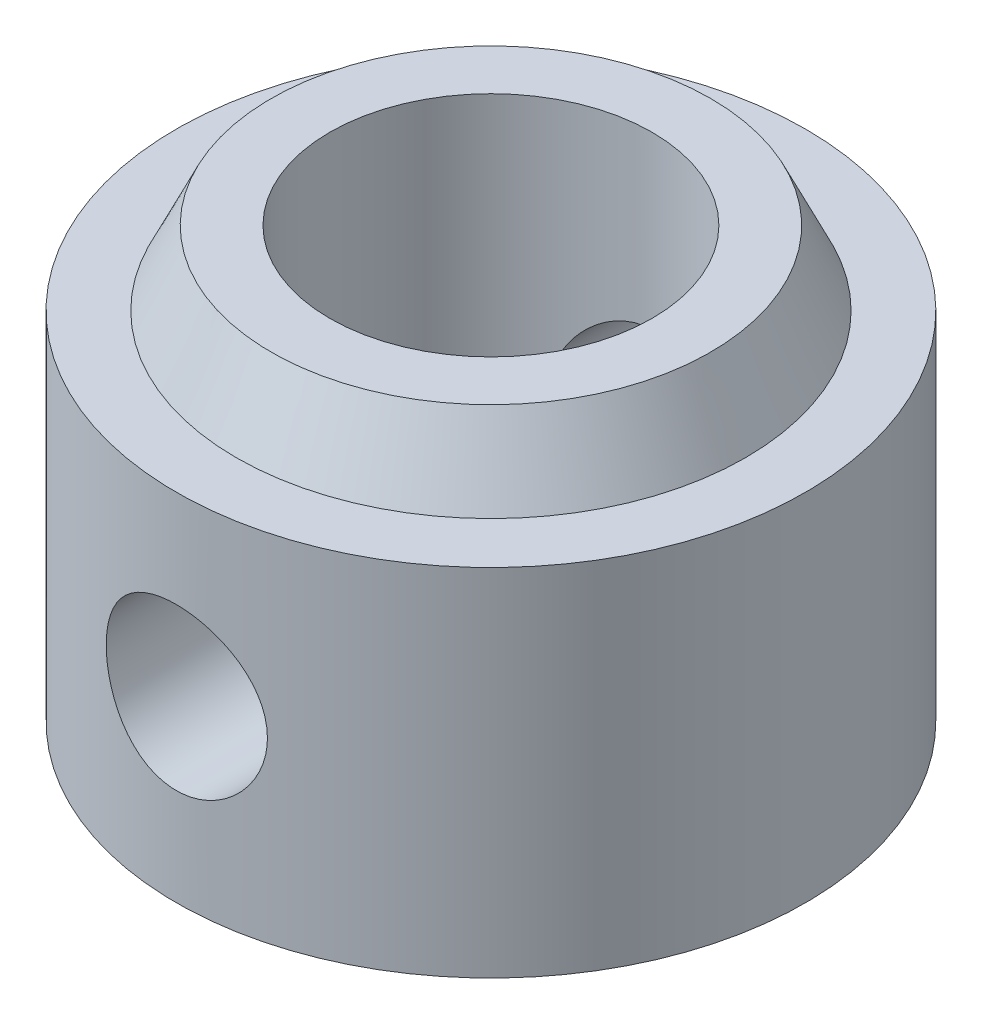
from build123d import *

# Parameters (mm, degrees)
M2_5X0_45_TAPPED_HOLE1_D = 2.05


with BuildPart() as part:
    # Sketch2 → Revolve1 (revolve)
    with BuildSketch(Plane.XY):
        Polygon((2.05, 5.461), (2.05, 0), (4.0005, 0), (4.0005, 4.5212), (3.2385, 4.5212), (2.794, 5.461), align=None)
    revolve(axis=Axis((0, 0, 0), (0, 1, 0)))

    # M2.5x0.45 Tapped Hole1 (through all)
    with Locations(Plane(origin=(0, 2.2606, 4.0005), x_dir=(1, 0, 0), z_dir=(0, 0, 1))):
        with Locations((0, 0)):
            Hole(M2_5X0_45_TAPPED_HOLE1_D / 2)


solid = part.part
